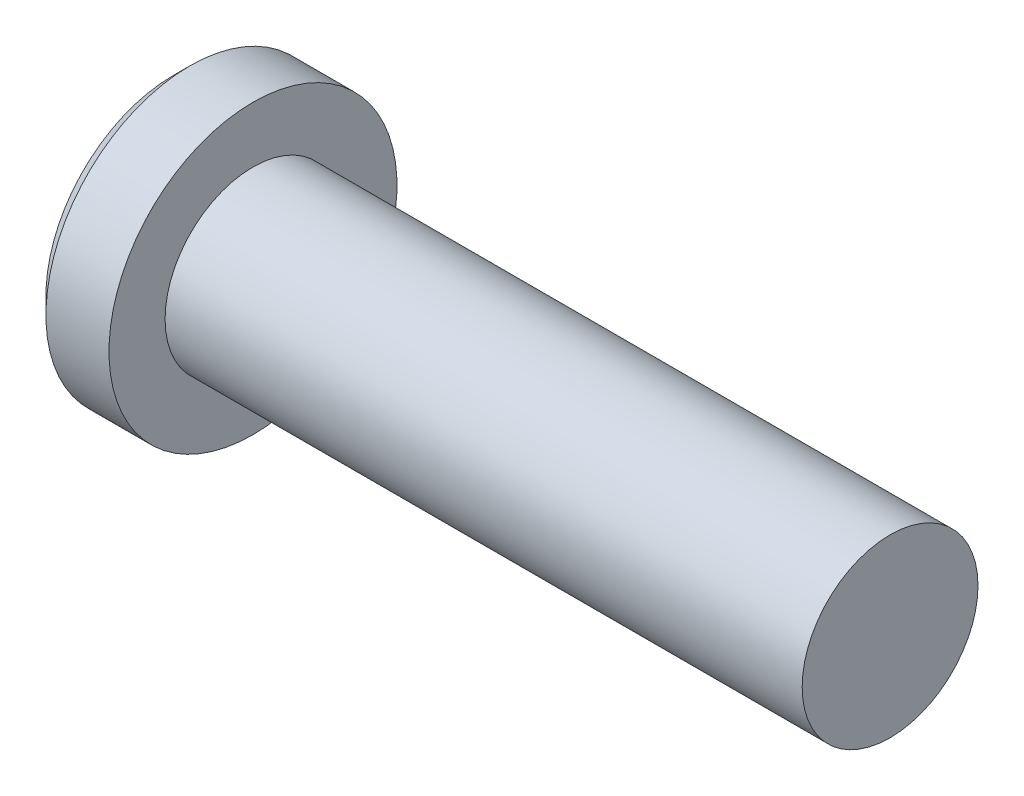
from build123d import *

# Parameters (mm, degrees)
SKETCH2_R           = 1.7526
BOSS_EXTRUDE1_DEPTH = 12.7


with BuildPart() as part:
    # Sketch2 → Boss-Extrude1 (new body)
    with BuildSketch(Plane(origin=(6.35, 0, 0), x_dir=(0, 0, -1), z_dir=(1, 0, 0))):
        Circle(SKETCH2_R)
    extrude(amount=-BOSS_EXTRUDE1_DEPTH)

    # Sketch6 → Revolve1 (revolve)
    with BuildSketch(Plane.XY):
        Polygon((-7.6073, 2.8702), (-7.9375, 2.54), (-7.9375, 0), (-6.35, 0), (-6.35, 2.8702), align=None)
    revolve(axis=Axis((-6.35, 0, 0), (-1, 0, 0)))


solid = part.part
